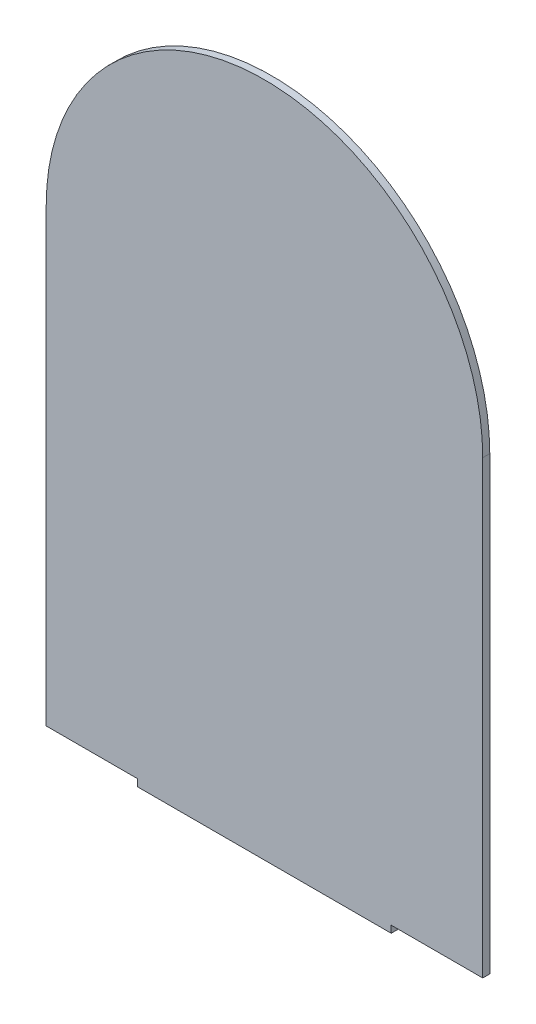
from build123d import *

# Parameters (mm, degrees)
BOSS_EXTRUDE1_DEPTH = 3.175


with BuildPart() as part:
    # Sketch2 → Boss-Extrude1 (new body)
    with BuildSketch(Plane.XY):
        with BuildLine():
            Line((0, 203.2), (0, 0))
            Line((0, 0), (41.275, 0))
            Line((41.275, 0), (41.275, -3.175))
            Line((41.275, -3.175), (155.575, -3.175))
            Line((155.575, -3.175), (155.575, 0))
            Line((155.575, 0), (196.85, 0))
            Line((196.85, 0), (196.85, 203.2))
            ThreePointArc((196.85, 203.2), (98.425, 301.625), (0, 203.2))
        make_face()
    extrude(amount=BOSS_EXTRUDE1_DEPTH)


solid = part.part
